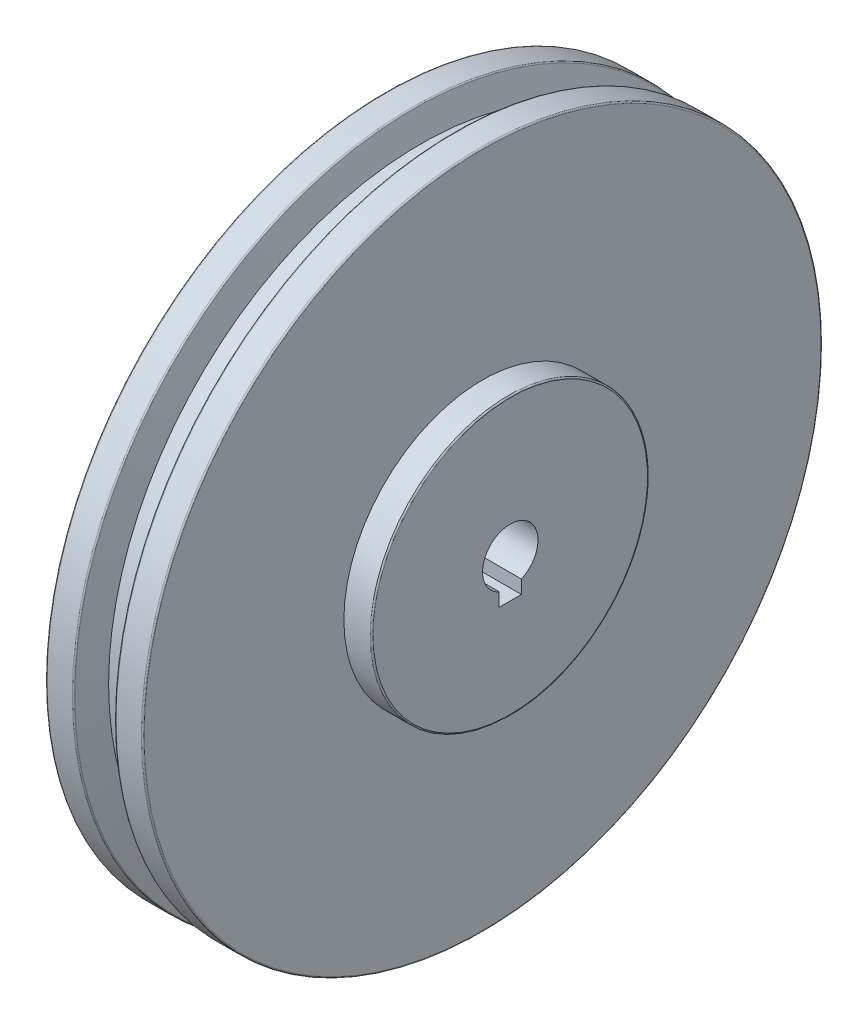
from build123d import *

# Parameters (mm, degrees)
ESBO_O1_W             = 8
ESBO_O1_H             = 8
CORTE_EXTRUS_O1_DEPTH = 46


with BuildPart() as part:
    # Sketch1 → Revolve1 (revolve)
    with BuildSketch(Plane.XY):
        with BuildLine():
            Line((0, -20), (0, -122))
            ThreePointArc((0, -122), (0.146446609, -122.353553391), (0.5, -122.5))
            Line((0.5, -122.5), (9.616336506, -122.5))
            ThreePointArc((9.616336506, -122.5), (9.920717221, -122.39667667), (10.099299419, -122.129409523))
            Line((10.099299419, -122.129409523), (12.679491924, -112.5))
            Line((12.679491924, -112.5), (22.320508076, -112.5))
            Line((22.320508076, -112.5), (24.900700581, -122.129409523))
            ThreePointArc((24.900700581, -122.129409523), (25.079282779, -122.39667667), (25.383663494, -122.5))
            Line((25.383663494, -122.5), (34.5, -122.5))
            ThreePointArc((34.5, -122.5), (34.853553391, -122.353553391), (35, -122))
            Line((35, -122), (35, -50))
            Line((35, -50), (44.5, -50))
            ThreePointArc((44.5, -50), (44.853553391, -49.853553391), (45, -49.5))
            Line((45, -49.5), (45, -10))
            Line((45, -10), (2.5, -10))
            Line((2.5, -10), (0, -20))
        make_face()
    revolve(axis=Axis((0, 0, 0), (1, 0, 0)))

    # Esboço1 → Corte-extrusão1 (cut, through all)
    with BuildSketch(Plane.ZY):
        with Locations((0, -10)):
            Rectangle(ESBO_O1_W, ESBO_O1_H)
    extrude(amount=-CORTE_EXTRUS_O1_DEPTH, mode=Mode.SUBTRACT)


solid = part.part
